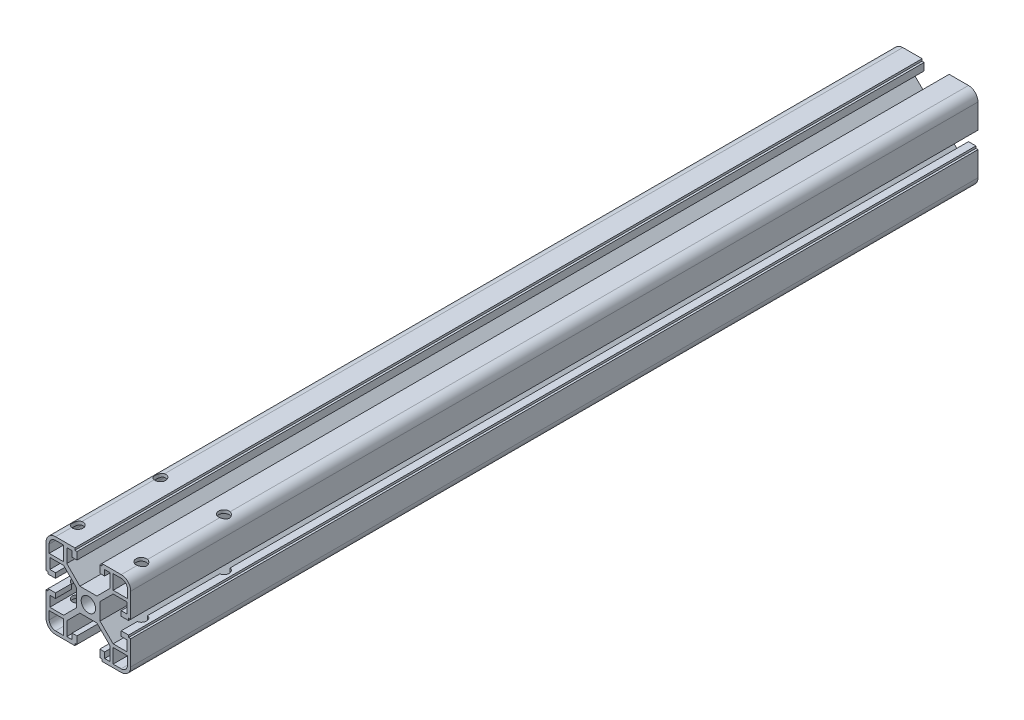
from build123d import *

# Parameters (mm, degrees)
BOSS_EXTRUDE1_DEPTH     = 400
MIRROR3_COPY_1_DEPTH    = 400
MIRROR3_COPY_2_DEPTH    = 400
SKETCH2_R               = 2.5
CUT_EXTRUDE1_DEPTH      = 15.5
CUT_EXTRUDE1_DEPTH_BACK = 26.5


with BuildPart() as part:
    # Sketch1 → Boss-Extrude1 (new body)
    with BuildSketch(Plane.XY):
        with BuildLine():
            Line((3.4, 0), (5.5, 0))
            Line((5.5, 0), (5.5, 4))
            Line((5.5, 4), (11.69, 10.19))
            Line((11.69, 10.19), (18.2, 10.19))
            Line((18.2, 10.19), (18.2, 5.265595036))
            Line((18.2, 5.265595036), (15.5, 5.265595036))
            Line((15.5, 5.265595036), (15.5, 2.965595036))
            Line((15.5, 2.965595036), (19, 2.965595036))
            Line((19, 2.965595036), (19, 3.965595036))
            Line((19, 3.965595036), (20, 3.965595036))
            Line((20, 3.965595036), (20, 15.5))
            ThreePointArc((20, 15.5), (18.681980515, 18.681980515), (15.5, 20))
            Line((15.5, 20), (6.385304712, 20))
            Line((6.385304712, 20), (6.385304712, 19))
            Line((6.385304712, 19), (5.385304712, 19))
            Line((5.385304712, 19), (5.385304712, 15.5))
            Line((5.385304712, 15.5), (7.685304712, 15.5))
            Line((7.685304712, 15.5), (7.685304712, 18.2))
            Line((7.685304712, 18.2), (10.19, 18.2))
            Line((10.19, 18.2), (10.19, 11.69))
            Line((10.19, 11.69), (4, 5.5))
            Line((4, 5.5), (0, 5.5))
            Line((0, 5.5), (0, 3.4))
            ThreePointArc((0, 3.4), (2.404163056, 2.404163056), (3.4, 0))
        make_face()
        with BuildLine():
            Line((18.5, 11.69), (18.5, 15.5))
            ThreePointArc((18.5, 15.5), (17.621320344, 17.621320344), (15.5, 18.5))
            Line((15.5, 18.5), (11.69, 18.5))
            Line((11.69, 18.5), (11.69, 11.69))
            Line((11.69, 11.69), (18.5, 11.69))
        make_face(mode=Mode.SUBTRACT)
    boss_extrude1 = extrude(amount=BOSS_EXTRUDE1_DEPTH)

    # Mirror1: Boss-Extrude1 across plane
    add(boss_extrude1.mirror(Plane.ZX))

    # Mirror2: Boss-Extrude1 across plane
    add(boss_extrude1.mirror(Plane(origin=(0, 0, 0), x_dir=(0, 0, 1), z_dir=(1, 0, 0))))

    # Mirror3 copy 1 sketch → Mirror3 copy 1 (add)
    with BuildSketch(Plane(origin=(0, 0, 0), x_dir=(-1, 0, 0), z_dir=(0, 0, 1))):
        with BuildLine():
            Line((3.4, 0), (5.5, 0))
            Line((5.5, 0), (5.5, 4))
            Line((5.5, 4), (11.69, 10.19))
            Line((11.69, 10.19), (18.2, 10.19))
            Line((18.2, 10.19), (18.2, 5.265595036))
            Line((18.2, 5.265595036), (15.5, 5.265595036))
            Line((15.5, 5.265595036), (15.5, 2.965595036))
            Line((15.5, 2.965595036), (19, 2.965595036))
            Line((19, 2.965595036), (19, 3.965595036))
            Line((19, 3.965595036), (20, 3.965595036))
            Line((20, 3.965595036), (20, 15.5))
            ThreePointArc((20, 15.5), (18.681980515, 18.681980515), (15.5, 20))
            Line((15.5, 20), (6.385304712, 20))
            Line((6.385304712, 20), (6.385304712, 19))
            Line((6.385304712, 19), (5.385304712, 19))
            Line((5.385304712, 19), (5.385304712, 15.5))
            Line((5.385304712, 15.5), (7.685304712, 15.5))
            Line((7.685304712, 15.5), (7.685304712, 18.2))
            Line((7.685304712, 18.2), (10.19, 18.2))
            Line((10.19, 18.2), (10.19, 11.69))
            Line((10.19, 11.69), (4, 5.5))
            Line((4, 5.5), (0, 5.5))
            Line((0, 5.5), (0, 3.4))
            ThreePointArc((0, 3.4), (2.404163056, 2.404163056), (3.4, 0))
        make_face()
        with BuildLine():
            Line((18.5, 11.69), (18.5, 15.5))
            ThreePointArc((18.5, 15.5), (17.621320344, 17.621320344), (15.5, 18.5))
            Line((15.5, 18.5), (11.69, 18.5))
            Line((11.69, 18.5), (11.69, 11.69))
            Line((11.69, 11.69), (18.5, 11.69))
        make_face(mode=Mode.SUBTRACT)
    extrude(amount=MIRROR3_COPY_1_DEPTH)

    # Mirror3 copy 2 sketch → Mirror3 copy 2 (add)
    with BuildSketch(Plane.XY):
        with BuildLine():
            Line((3.4, 0), (5.5, 0))
            Line((5.5, 0), (5.5, -4))
            Line((5.5, -4), (11.69, -10.19))
            Line((11.69, -10.19), (18.2, -10.19))
            Line((18.2, -10.19), (18.2, -5.265595036))
            Line((18.2, -5.265595036), (15.5, -5.265595036))
            Line((15.5, -5.265595036), (15.5, -2.965595036))
            Line((15.5, -2.965595036), (19, -2.965595036))
            Line((19, -2.965595036), (19, -3.965595036))
            Line((19, -3.965595036), (20, -3.965595036))
            Line((20, -3.965595036), (20, -15.5))
            ThreePointArc((20, -15.5), (18.681980515, -18.681980515), (15.5, -20))
            Line((15.5, -20), (6.385304712, -20))
            Line((6.385304712, -20), (6.385304712, -19))
            Line((6.385304712, -19), (5.385304712, -19))
            Line((5.385304712, -19), (5.385304712, -15.5))
            Line((5.385304712, -15.5), (7.685304712, -15.5))
            Line((7.685304712, -15.5), (7.685304712, -18.2))
            Line((7.685304712, -18.2), (10.19, -18.2))
            Line((10.19, -18.2), (10.19, -11.69))
            Line((10.19, -11.69), (4, -5.5))
            Line((4, -5.5), (0, -5.5))
            Line((0, -5.5), (0, -3.4))
            ThreePointArc((0, -3.4), (2.404163056, -2.404163056), (3.4, 0))
        make_face()
        with BuildLine():
            Line((18.5, -11.69), (18.5, -15.5))
            ThreePointArc((18.5, -15.5), (17.621320344, -17.621320344), (15.5, -18.5))
            Line((15.5, -18.5), (11.69, -18.5))
            Line((11.69, -18.5), (11.69, -11.69))
            Line((11.69, -11.69), (18.5, -11.69))
        make_face(mode=Mode.SUBTRACT)
    extrude(amount=MIRROR3_COPY_2_DEPTH)

    # Sketch2 → Cut-Extrude1 (cut, two sides)
    with BuildSketch(Plane(origin=(0, 5.5, 0), x_dir=(1, 0, 0), z_dir=(0, 1, 0))) as cut_extrude1_sk:
        with Locations((0, -10)):
            Circle(SKETCH2_R)
        with Locations((0, -60)):
            Circle(SKETCH2_R)
        with Locations((-15, -351)):
            Circle(SKETCH2_R)
        with Locations((15, -351)):
            Circle(SKETCH2_R)
        with Locations((15, -390)):
            Circle(SKETCH2_R)
        with Locations((-15, -390)):
            Circle(SKETCH2_R)
    extrude(amount=CUT_EXTRUDE1_DEPTH, mode=Mode.SUBTRACT)
    extrude(cut_extrude1_sk.sketch, amount=-CUT_EXTRUDE1_DEPTH_BACK, mode=Mode.SUBTRACT)


solid = part.part
